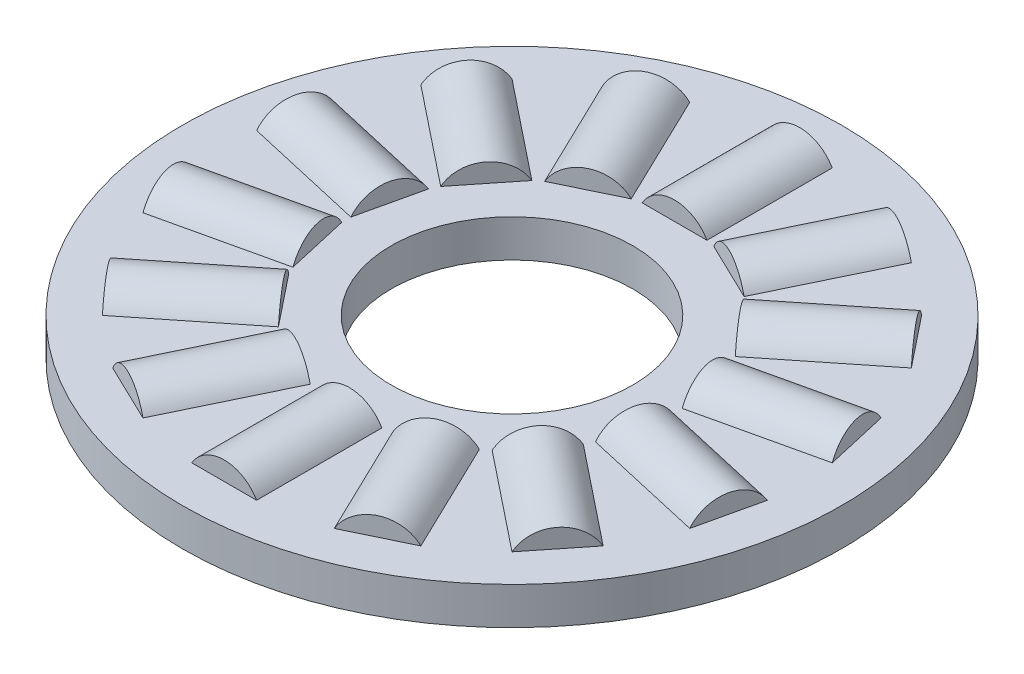
from build123d import *

# Parameters (mm, degrees)
SKETCH5_W         = 5.53085
SKETCH5_H         = 0.9921875
SKETCH3_W         = 3.31851
SKETCH3_H         = 0.9921875
SKETCH2_W         = 3.31851
SKETCH2_H         = 0.9921875
CIRPATTERN1_COUNT = 14
CIRPATTERN1_ANGLE = 334.285714286
CIRPATTERN2_COUNT = 14


with BuildPart() as part:
    # Sketch5 → Revolve3 (revolve)
    with BuildSketch(Plane(origin=(0, 0, 0), x_dir=(0, 0, -1), z_dir=(1, 0, 0))):
        with Locations((-5.965825, 0)):
            Rectangle(SKETCH5_W, SKETCH5_H)
    revolve(axis=Axis((0, -0.9921875, 0), (0, 1, 0)))

    # Sketch3 → Cut-Revolve1 (revolve, cut)
    with BuildSketch(Plane(origin=(0, 0, 0), x_dir=(0, 0, -1), z_dir=(1, 0, 0))):
        with Locations((-5.965825, 0.49609375)):
            Rectangle(SKETCH3_W, SKETCH3_H)
    cut_revolve1 = revolve(axis=Axis((0, 0, 7.62508), (0, 0, -1)), mode=Mode.SUBTRACT)

    # CirPattern2: Cut-Revolve1 ×14 about axis
    cirpattern2_axis = Axis((0, 0.9921875, 0), (0, -1, 0))
    for i in range(1, CIRPATTERN2_COUNT):
        add(cut_revolve1.rotate(cirpattern2_axis, i * 360 / CIRPATTERN2_COUNT), mode=Mode.SUBTRACT)


with BuildPart() as body_2:
    # Sketch2 → Revolve2 (revolve)
    with BuildSketch(Plane(origin=(0, 0, 0), x_dir=(0, 0, -1), z_dir=(1, 0, 0))):
        with Locations((-5.965825, 0.49609375)):
            Rectangle(SKETCH2_W, SKETCH2_H)
    revolve(axis=Axis((0, 0, 7.62508), (0, 0, -1)))


with BuildPart() as cirpattern1_1:
    # CirPattern1: pattern copy
    add(body_2.part.rotate(Axis((0, 0.9921875, 0), (0, -1, 0)), 1 * CIRPATTERN1_ANGLE / (CIRPATTERN1_COUNT - 1)))


with BuildPart() as cirpattern1_2:
    # CirPattern1: pattern copy
    add(body_2.part.rotate(Axis((0, 0.9921875, 0), (0, -1, 0)), 2 * CIRPATTERN1_ANGLE / (CIRPATTERN1_COUNT - 1)))


with BuildPart() as cirpattern1_3:
    # CirPattern1: pattern copy
    add(body_2.part.rotate(Axis((0, 0.9921875, 0), (0, -1, 0)), 3 * CIRPATTERN1_ANGLE / (CIRPATTERN1_COUNT - 1)))


with BuildPart() as cirpattern1_4:
    # CirPattern1: pattern copy
    add(body_2.part.rotate(Axis((0, 0.9921875, 0), (0, -1, 0)), 4 * CIRPATTERN1_ANGLE / (CIRPATTERN1_COUNT - 1)))


with BuildPart() as cirpattern1_5:
    # CirPattern1: pattern copy
    add(body_2.part.rotate(Axis((0, 0.9921875, 0), (0, -1, 0)), 5 * CIRPATTERN1_ANGLE / (CIRPATTERN1_COUNT - 1)))


with BuildPart() as cirpattern1_6:
    # CirPattern1: pattern copy
    add(body_2.part.rotate(Axis((0, 0.9921875, 0), (0, -1, 0)), 6 * CIRPATTERN1_ANGLE / (CIRPATTERN1_COUNT - 1)))


with BuildPart() as cirpattern1_7:
    # CirPattern1: pattern copy
    add(body_2.part.rotate(Axis((0, 0.9921875, 0), (0, -1, 0)), 7 * CIRPATTERN1_ANGLE / (CIRPATTERN1_COUNT - 1)))


with BuildPart() as cirpattern1_8:
    # CirPattern1: pattern copy
    add(body_2.part.rotate(Axis((0, 0.9921875, 0), (0, -1, 0)), 8 * CIRPATTERN1_ANGLE / (CIRPATTERN1_COUNT - 1)))


with BuildPart() as cirpattern1_9:
    # CirPattern1: pattern copy
    add(body_2.part.rotate(Axis((0, 0.9921875, 0), (0, -1, 0)), 9 * CIRPATTERN1_ANGLE / (CIRPATTERN1_COUNT - 1)))


with BuildPart() as cirpattern1_10:
    # CirPattern1: pattern copy
    add(body_2.part.rotate(Axis((0, 0.9921875, 0), (0, -1, 0)), 10 * CIRPATTERN1_ANGLE / (CIRPATTERN1_COUNT - 1)))


with BuildPart() as cirpattern1_11:
    # CirPattern1: pattern copy
    add(body_2.part.rotate(Axis((0, 0.9921875, 0), (0, -1, 0)), 11 * CIRPATTERN1_ANGLE / (CIRPATTERN1_COUNT - 1)))


with BuildPart() as cirpattern1_12:
    # CirPattern1: pattern copy
    add(body_2.part.rotate(Axis((0, 0.9921875, 0), (0, -1, 0)), 12 * CIRPATTERN1_ANGLE / (CIRPATTERN1_COUNT - 1)))


with BuildPart() as cirpattern1_13:
    # CirPattern1: pattern copy
    add(body_2.part.rotate(Axis((0, 0.9921875, 0), (0, -1, 0)), 13 * CIRPATTERN1_ANGLE / (CIRPATTERN1_COUNT - 1)))


solid = Compound([part.part, body_2.part, cirpattern1_1.part, cirpattern1_2.part, cirpattern1_3.part, cirpattern1_4.part, cirpattern1_5.part, cirpattern1_6.part, cirpattern1_7.part, cirpattern1_8.part, cirpattern1_9.part, cirpattern1_10.part, cirpattern1_11.part, cirpattern1_12.part, cirpattern1_13.part])
